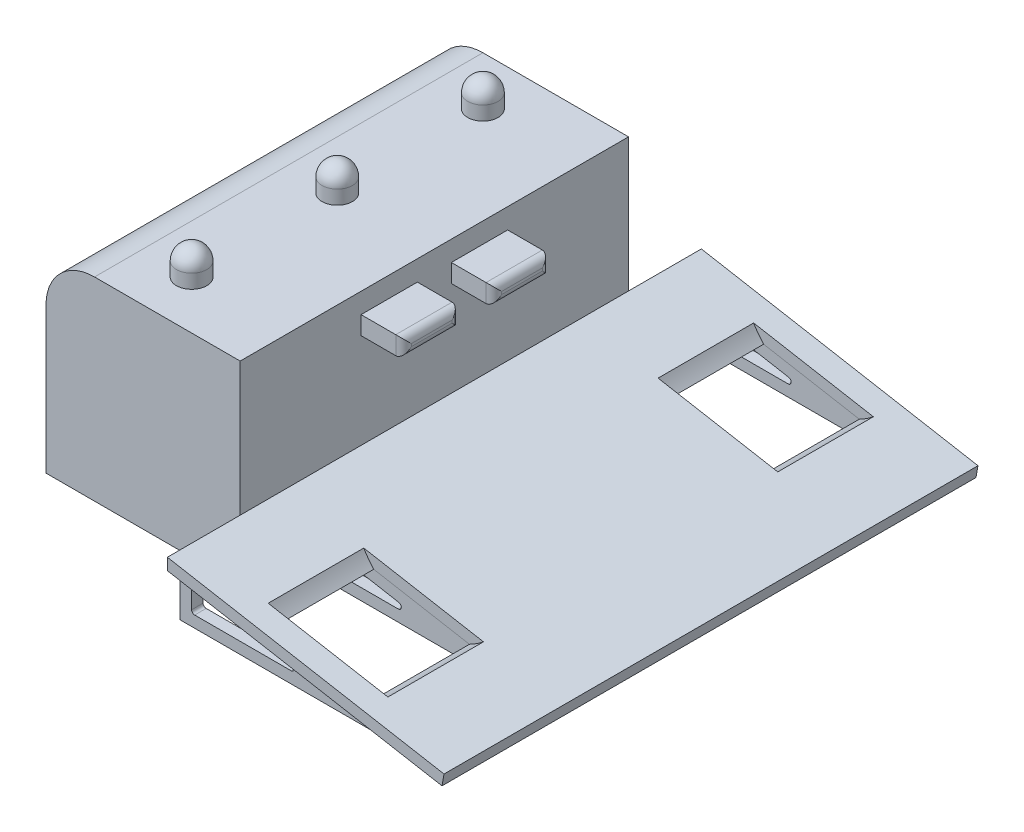
from build123d import *

# Parameters (mm, degrees)
EXTRUDE1_DEPTH   = 50.8
SHELL1_T         = -1.5875
EXTRUDE2_REACH   = 52.8
SKETCH2_R        = 1.524
EXTRUDE3_DEPTH   = 69.85
EXTRUDE4_DEPTH   = 25
SKETCH5_W        = 14.732
SKETCH5_H        = 4.7625
EXTRUDE5_DEPTH   = 11.1125
EXTRUDE5_2_DEPTH = 11.1125
FILLET3_R        = 2.032
FILLET4_R        = 2.032
SKETCH6_R        = 3.96875
EXTRUDE6_DEPTH   = 7.62
EXTRUDE6_2_DEPTH = 7.62
EXTRUDE6_3_DEPTH = 7.62
FILLET5_R        = 3.96875
FILLET6_R        = 3.96875
FILLET7_R        = 3.96875
EXTRUDE7_DEPTH   = 2.9972
EXTRUDE8_DEPTH   = 2.9972


with BuildPart() as part:
    # Sketch1 → Extrude1 (new body, symmetric)
    with BuildSketch(Plane.XY):
        with BuildLine():
            Line((-12.7, 50.8), (25.4, 50.8))
            Line((25.4, 50.8), (25.4, 0))
            Line((25.4, 0), (-25.4, 0))
            Line((-25.4, 0), (-25.4, 38.1))
            ThreePointArc((-25.4, 38.1), (-21.680256121, 47.080256121), (-12.7, 50.8))
        make_face()
    extrude(amount=EXTRUDE1_DEPTH, both=True)

    # Shell1
    shell1_openings = [part.faces().sort_by_distance(p)[0] for p in [
        (0, 0, 0),
    ]]
    offset(amount=SHELL1_T, openings=shell1_openings, kind=Kind.INTERSECTION)

    # Sketch2 → Extrude2 (cut, up to next)
    with BuildSketch(Plane(origin=(0, 50.8, 0), x_dir=(-1, 0, 0), z_dir=(0, 1, 0)), mode=Mode.PRIVATE) as extrude2_sk1:
        with Locations(Location((0, 0, 0), (0, 0, 90))):  # turned: the seam where the file's is
            Circle(SKETCH2_R)
    extrude2_tool1 = extrude(extrude2_sk1.sketch, amount=-EXTRUDE2_REACH, mode=Mode.PRIVATE) & part.part
    add(extrude2_tool1.solids().sort_by_distance((0, 50.8, 0))[0], mode=Mode.SUBTRACT)
    # Sketch2 → Extrude2 (cut, up to next)
    with BuildSketch(Plane(origin=(0, 50.8, 0), x_dir=(-1, 0, 0), z_dir=(0, 1, 0)), mode=Mode.PRIVATE) as extrude2_sk2:
        with Locations(Location((0, -38.1, 0), (0, 0, 90))):  # turned: the seam where the file's is
            Circle(SKETCH2_R)
    extrude2_tool2 = extrude(extrude2_sk2.sketch, amount=-EXTRUDE2_REACH, mode=Mode.PRIVATE) & part.part
    add(extrude2_tool2.solids().sort_by_distance((0, 50.8, -38.1))[0], mode=Mode.SUBTRACT)
    # Sketch2 → Extrude2 (cut, up to next)
    with BuildSketch(Plane(origin=(0, 50.8, 0), x_dir=(-1, 0, 0), z_dir=(0, 1, 0)), mode=Mode.PRIVATE) as extrude2_sk3:
        with Locations(Location((0, 38.1, 0), (0, 0, 90))):  # turned: the seam where the file's is
            Circle(SKETCH2_R)
    extrude2_tool3 = extrude(extrude2_sk3.sketch, amount=-EXTRUDE2_REACH, mode=Mode.PRIVATE) & part.part
    add(extrude2_tool3.solids().sort_by_distance((0, 50.8, 38.1))[0], mode=Mode.SUBTRACT)


with BuildPart() as body_2:
    # Sketch3 → Extrude3 (new body, symmetric)
    with BuildSketch(Plane.XY):
        Polygon((25.4, 15.875), (97.777052556, 2.950526329), (97.250172854, 0), (25.4, 12.83038801), align=None)
    extrude(amount=EXTRUDE3_DEPTH, both=True)

    # Sketch4 → Extrude4 (cut)
    with BuildSketch(Plane.XY.offset(63.5)):
        with BuildLine():
            Line((76.747589944, 6.70578751), (45.431643678, 12.297920772))
            ThreePointArc((45.431643678, 12.297920772), (59.808396592, 2.327020914), (76.747589944, 6.70578751))
        make_face()
    extrude4 = extrude(amount=-EXTRUDE4_DEPTH, mode=Mode.SUBTRACT)

    # Mirror1: Extrude4 across plane
    add(extrude4.mirror(Plane.XY), mode=Mode.SUBTRACT)


with BuildPart() as body_3:
    # Sketch5 → Extrude5 (new body)
    with BuildSketch(Plane(origin=(25.4, 0, 0), x_dir=(0, 0, -1), z_dir=(1, 0, 0))):
        with Locations((-11.811, 43.123528776)):
            Rectangle(SKETCH5_W, SKETCH5_H)
    extrude(amount=EXTRUDE5_DEPTH)

    # Fillet3
    fillet3_edges = [body_3.edges().sort_by_distance(p)[0] for p in [
        (36.5125, 43.123528776, 4.445),
        (36.5125, 45.504778776, 11.811),
        (36.5125, 43.123528776, 19.177),
        (36.5125, 40.742278776, 11.811),
    ]]
    fillet(fillet3_edges, radius=FILLET3_R)


with BuildPart() as body_4:
    # Sketch5 → Extrude5 2 (new body)
    with BuildSketch(Plane(origin=(25.4, 0, 0), x_dir=(0, 0, -1), z_dir=(1, 0, 0))):
        with Locations((11.811, 43.123528776)):
            Rectangle(SKETCH5_W, SKETCH5_H)
    extrude(amount=EXTRUDE5_2_DEPTH)

    # Fillet4
    fillet4_edges = [body_4.edges().sort_by_distance(p)[0] for p in [
        (36.5125, 40.742278776, -11.811),
        (36.5125, 43.123528776, -19.177),
        (36.5125, 45.504778776, -11.811),
        (36.5125, 43.123528776, -4.445),
    ]]
    fillet(fillet4_edges, radius=FILLET4_R)


with BuildPart() as body_5:
    # Sketch6 → Extrude6 (new body)
    with BuildSketch(Plane(origin=(0, 50.8, 0), x_dir=(1, 0, 0), z_dir=(0, 1, 0))):
        with Locations(Location((0, 38.1, 0), (0, 0, 270))):  # turned: the seam where the file's is
            Circle(SKETCH6_R)
    extrude(amount=EXTRUDE6_DEPTH)

    # Fillet7
    fillet7_edges = [body_5.edges().sort_by_distance(p)[0] for p in [
        (0, 58.42, -42.06875),
    ]]
    fillet(fillet7_edges, radius=FILLET7_R)


with BuildPart() as body_6:
    # Sketch6 → Extrude6 2 (new body)
    with BuildSketch(Plane(origin=(0, 50.8, 0), x_dir=(1, 0, 0), z_dir=(0, 1, 0))):
        with Locations(Location((0, 0, 0), (0, 0, 270))):  # turned: the seam where the file's is
            Circle(SKETCH6_R)
    extrude(amount=EXTRUDE6_2_DEPTH)

    # Fillet6
    fillet6_edges = [body_6.edges().sort_by_distance(p)[0] for p in [
        (0, 58.42, -3.96875),
    ]]
    fillet(fillet6_edges, radius=FILLET6_R)


with BuildPart() as body_7:
    # Sketch6 → Extrude6 3 (new body)
    with BuildSketch(Plane(origin=(0, 50.8, 0), x_dir=(1, 0, 0), z_dir=(0, 1, 0))):
        with Locations(Location((0, -38.1, 0), (0, 0, 270))):  # turned: the seam where the file's is
            Circle(SKETCH6_R)
    extrude(amount=EXTRUDE6_3_DEPTH)

    # Fillet5
    fillet5_edges = [body_7.edges().sort_by_distance(p)[0] for p in [
        (0, 58.42, 34.13125),
    ]]
    fillet(fillet5_edges, radius=FILLET5_R)


with BuildPart() as body_8:
    # Sketch7 → Extrude7 (new body)
    with BuildSketch(Plane.XY.offset(63.5)):
        Polygon((25.4, 12.83038801), (25.4, 0), (97.250172854, 0), align=None)
        with BuildLine():
            Line((54.595245135, 4.572339388), (29.330483819, 9.083903909))
            ThreePointArc((29.330483819, 9.083903909), (28.681399172, 8.911117031), (28.3972, 8.302514521))
            Line((28.3972, 8.302514521), (28.3972, 3.79095))
            ThreePointArc((28.3972, 3.79095), (28.629683992, 3.229683992), (29.19095, 2.9972))
            Line((29.19095, 2.9972), (54.455711316, 2.9972))
            ThreePointArc((54.455711316, 2.9972), (55.246365124, 3.720909884), (54.595245135, 4.572339388))
        make_face(mode=Mode.SUBTRACT)
    extrude(amount=EXTRUDE7_DEPTH)


with BuildPart() as body_9:
    # Sketch8 → Extrude8 (new body)
    with BuildSketch(Plane.XY.offset(38.5)):
        Polygon((97.250172854, 0), (25.4, 12.83038801), (25.4, 0), align=None)
        with BuildLine():
            Line((28.3972, 8.302514521), (28.3972, 3.79095))
            ThreePointArc((28.3972, 3.79095), (28.629683992, 3.229683992), (29.19095, 2.9972))
            Line((29.19095, 2.9972), (54.455711316, 2.9972))
            ThreePointArc((54.455711316, 2.9972), (55.246365124, 3.720909884), (54.595245135, 4.572339388))
            Line((54.595245135, 4.572339388), (29.330483819, 9.083903909))
            ThreePointArc((29.330483819, 9.083903909), (28.681399172, 8.911117031), (28.3972, 8.302514521))
        make_face(mode=Mode.SUBTRACT)
    extrude(amount=-EXTRUDE8_DEPTH)


with BuildPart() as body_10:
    # Mirror2: mirrored copy
    add(body_8.part.mirror(Plane.XY))


with BuildPart() as body_11:
    # Mirror2 2: mirrored copy
    add(body_9.part.mirror(Plane.XY))


solid = Compound([part.part, body_2.part, body_3.part, body_4.part, body_5.part, body_6.part, body_7.part, body_8.part, body_9.part, body_10.part, body_11.part])
